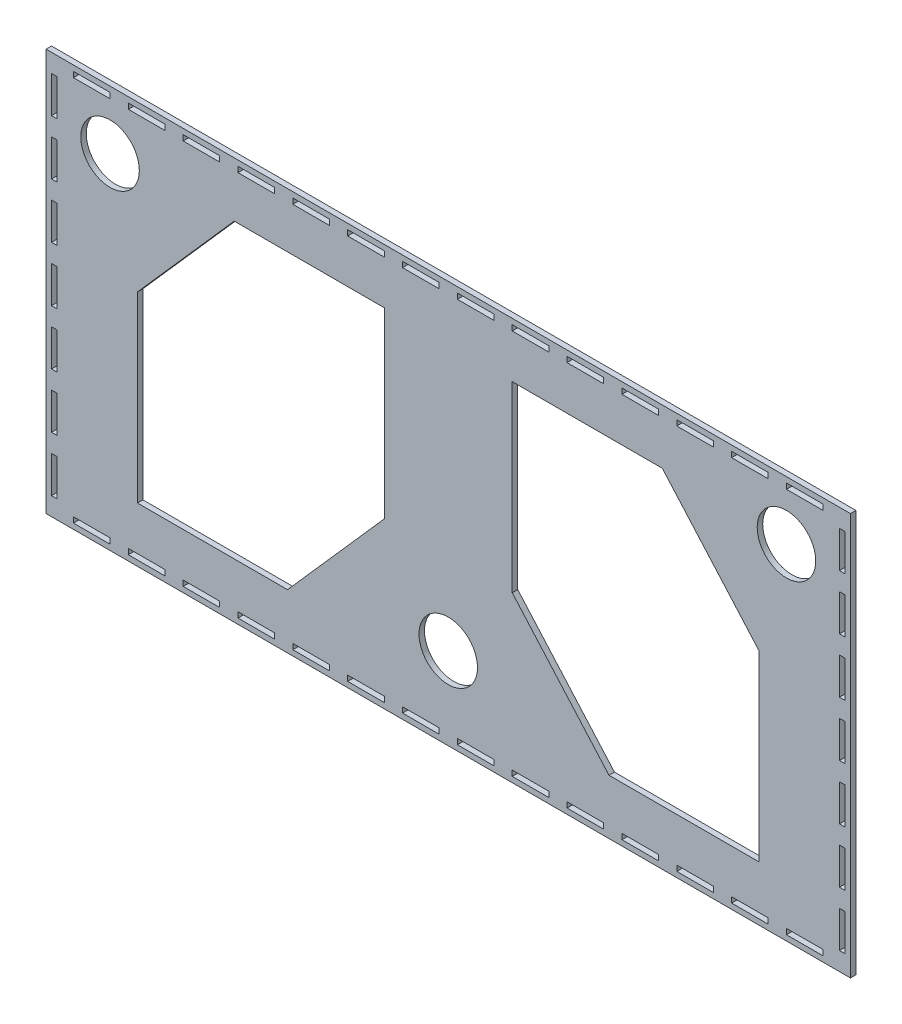
from build123d import *

# Parameters (mm, degrees)
ESQUISSE1_W                      = 440
ESQUISSE1_H                      = 220
BOSS_EXTRU_1_DEPTH               = 3
ESQUISSE2_R                      = 16
ENL_V_MAT_TUBE_DEPTH             = 3
ESQUISSE4_W                      = 20
ESQUISSE4_H                      = 3
ENL_V_MAT_C_T_ARRI_REBOITE_DEPTH = 3
ESQUISSE5_W                      = 3
ESQUISSE5_H                      = 20
ENL_V_MAT_C_T_DGBOITE_DEPTH      = 3
ENL_V_MAT_EXTRU_1_DEPTH          = 3


with BuildPart() as part:
    # Esquisse1 → Boss.-Extru.1 (new body)
    with BuildSketch(Plane.XY):
        Rectangle(ESQUISSE1_W, ESQUISSE1_H)
    extrude(amount=BOSS_EXTRU_1_DEPTH)

    # Esquisse2 → Enlèv. mat._Tube (cut)
    with BuildSketch(Plane(origin=(0, 0, 0), x_dir=(-1, 0, 0), z_dir=(0, 0, -1))):
        with Locations((-185, 78)):
            Circle(ESQUISSE2_R)
        with Locations((185, 78)):
            Circle(ESQUISSE2_R)
        with Locations((0, -65)):
            Circle(ESQUISSE2_R)
    extrude(amount=-ENL_V_MAT_TUBE_DEPTH, mode=Mode.SUBTRACT)

    # Esquisse4 → Enlèv. mat._CôtéArrièreBoite (cut)
    with BuildSketch(Plane(origin=(0, 0, 0), x_dir=(-1, 0, 0), z_dir=(0, 0, -1))):
        with Locations((-195, 105.5)):
            Rectangle(ESQUISSE4_W, ESQUISSE4_H)
        with Locations((-165, 105.5)):
            Rectangle(ESQUISSE4_W, ESQUISSE4_H)
        with Locations((-135, 105.5)):
            Rectangle(ESQUISSE4_W, ESQUISSE4_H)
        with Locations((-105, 105.5)):
            Rectangle(ESQUISSE4_W, ESQUISSE4_H)
        with Locations((-75, 105.5)):
            Rectangle(ESQUISSE4_W, ESQUISSE4_H)
        with Locations((-45, 105.5)):
            Rectangle(ESQUISSE4_W, ESQUISSE4_H)
        with Locations((-15, 105.5)):
            Rectangle(ESQUISSE4_W, ESQUISSE4_H)
        with Locations((15, 105.5)):
            Rectangle(ESQUISSE4_W, ESQUISSE4_H)
        with Locations((45, 105.5)):
            Rectangle(ESQUISSE4_W, ESQUISSE4_H)
        with Locations((75, 105.5)):
            Rectangle(ESQUISSE4_W, ESQUISSE4_H)
        with Locations((105, 105.5)):
            Rectangle(ESQUISSE4_W, ESQUISSE4_H)
        with Locations((135, 105.5)):
            Rectangle(ESQUISSE4_W, ESQUISSE4_H)
        with Locations((165, 105.5)):
            Rectangle(ESQUISSE4_W, ESQUISSE4_H)
        with Locations((195, 105.5)):
            Rectangle(ESQUISSE4_W, ESQUISSE4_H)
        with Locations((105, -105.5)):
            Rectangle(ESQUISSE4_W, ESQUISSE4_H)
        with Locations((135, -105.5)):
            Rectangle(ESQUISSE4_W, ESQUISSE4_H)
        with Locations((165, -105.5)):
            Rectangle(ESQUISSE4_W, ESQUISSE4_H)
        with Locations((195, -105.5)):
            Rectangle(ESQUISSE4_W, ESQUISSE4_H)
        with Locations((75, -105.5)):
            Rectangle(ESQUISSE4_W, ESQUISSE4_H)
        with Locations((45, -105.5)):
            Rectangle(ESQUISSE4_W, ESQUISSE4_H)
        with Locations((15, -105.5)):
            Rectangle(ESQUISSE4_W, ESQUISSE4_H)
        with Locations((-15, -105.5)):
            Rectangle(ESQUISSE4_W, ESQUISSE4_H)
        with Locations((-45, -105.5)):
            Rectangle(ESQUISSE4_W, ESQUISSE4_H)
        with Locations((-75, -105.5)):
            Rectangle(ESQUISSE4_W, ESQUISSE4_H)
        with Locations((-105, -105.5)):
            Rectangle(ESQUISSE4_W, ESQUISSE4_H)
        with Locations((-135, -105.5)):
            Rectangle(ESQUISSE4_W, ESQUISSE4_H)
        with Locations((-165, -105.5)):
            Rectangle(ESQUISSE4_W, ESQUISSE4_H)
        with Locations((-195, -105.5)):
            Rectangle(ESQUISSE4_W, ESQUISSE4_H)
    extrude(amount=-ENL_V_MAT_C_T_ARRI_REBOITE_DEPTH, mode=Mode.SUBTRACT)

    # Esquisse5 → Enlèv. mat.-CôtéDGBoite (cut)
    with BuildSketch(Plane(origin=(0, 0, 0), x_dir=(-1, 0, 0), z_dir=(0, 0, -1))):
        with Locations((-215.5, -90)):
            Rectangle(ESQUISSE5_W, ESQUISSE5_H)
        with Locations((-215.5, -60)):
            Rectangle(ESQUISSE5_W, ESQUISSE5_H)
        with Locations((-215.5, -30)):
            Rectangle(ESQUISSE5_W, ESQUISSE5_H)
        with Locations((-215.5, 0)):
            Rectangle(ESQUISSE5_W, ESQUISSE5_H)
        with Locations((-215.5, 30)):
            Rectangle(ESQUISSE5_W, ESQUISSE5_H)
        with Locations((-215.5, 60)):
            Rectangle(ESQUISSE5_W, ESQUISSE5_H)
        with Locations((-215.5, 90)):
            Rectangle(ESQUISSE5_W, ESQUISSE5_H)
        with Locations((215.5, 90)):
            Rectangle(ESQUISSE5_W, ESQUISSE5_H)
        with Locations((215.5, 60)):
            Rectangle(ESQUISSE5_W, ESQUISSE5_H)
        with Locations((215.5, 30)):
            Rectangle(ESQUISSE5_W, ESQUISSE5_H)
        with Locations((215.5, 0)):
            Rectangle(ESQUISSE5_W, ESQUISSE5_H)
        with Locations((215.5, -30)):
            Rectangle(ESQUISSE5_W, ESQUISSE5_H)
        with Locations((215.5, -60)):
            Rectangle(ESQUISSE5_W, ESQUISSE5_H)
        with Locations((215.5, -90)):
            Rectangle(ESQUISSE5_W, ESQUISSE5_H)
    extrude(amount=-ENL_V_MAT_C_T_DGBOITE_DEPTH, mode=Mode.SUBTRACT)

    # Esquisse6 → Enlèv. mat.-Extru.1 (cut)
    with BuildSketch(Plane(origin=(0, 0, 0), x_dir=(-1, 0, 0), z_dir=(0, 0, -1))):
        Polygon((-170, 20), (-117.084973779, 80), (-35, 80), (-35, -20), (-87.915026221, -80), (-170, -80), align=None)
        Polygon((170, 20), (170, -80), (87.915026221, -80), (35, -20), (35, 80), (117.084973779, 80), align=None)
    extrude(amount=-ENL_V_MAT_EXTRU_1_DEPTH, mode=Mode.SUBTRACT)


solid = part.part
